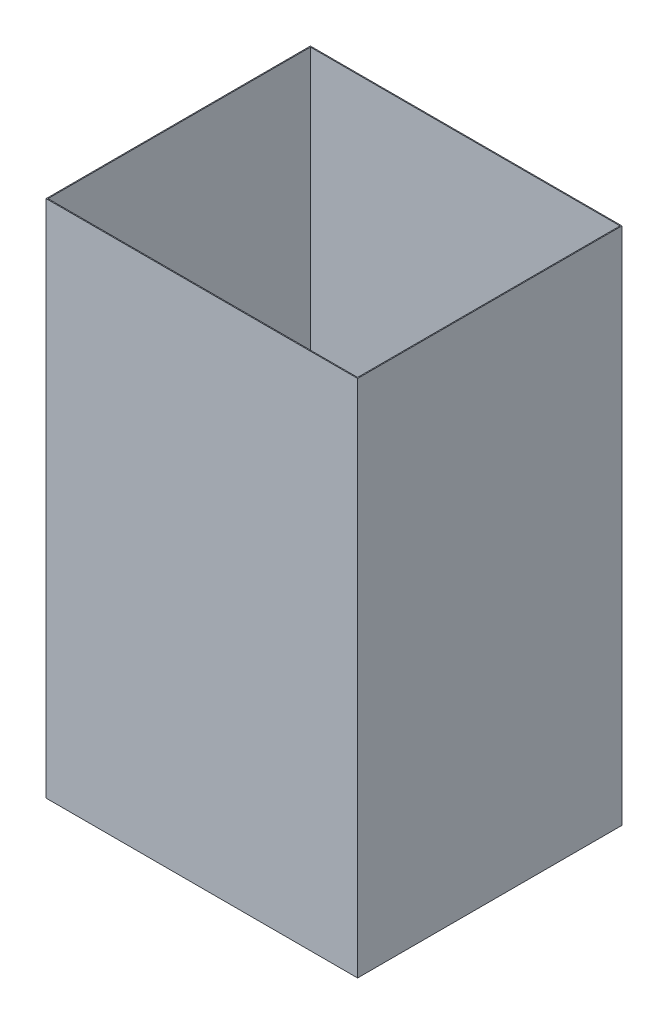
from build123d import *

# Parameters (mm, degrees)
SKETCH1_W           = 838.2
SKETCH1_H           = 711.2
BOSS_EXTRUDE1_DEPTH = 1397
SHELL1_T            = -2.54
CUT_EXTRUDE1_REACH  = 4.54
SKETCH2_W           = 833.12
SKETCH2_H           = 706.12


with BuildPart() as part:
    # Sketch1 → Boss-Extrude1 (new body)
    with BuildSketch(Plane(origin=(0, 0, 0), x_dir=(1, 0, 0), z_dir=(0, 1, 0))):
        with Locations((419.1, 355.6)):
            Rectangle(SKETCH1_W, SKETCH1_H)
    extrude(amount=BOSS_EXTRUDE1_DEPTH)

    # Shell1
    shell1_openings = [part.faces().sort_by_distance(p)[0] for p in [
        (419.1, 0, -355.6),
    ]]
    offset(amount=SHELL1_T, openings=shell1_openings, kind=Kind.INTERSECTION)

    # Sketch2 → Cut-Extrude1 (cut, up to next)
    with BuildSketch(Plane.XZ.offset(-1394.46), mode=Mode.PRIVATE) as cut_extrude1_sk1:
        with Locations((419.1, -355.6)):
            Rectangle(SKETCH2_W, SKETCH2_H)
    cut_extrude1_tool1 = extrude(cut_extrude1_sk1.sketch, amount=-CUT_EXTRUDE1_REACH, mode=Mode.PRIVATE) & part.part
    add(cut_extrude1_tool1.solids().sort_by_distance((419.1, 1394.46, -355.6))[0], mode=Mode.SUBTRACT)


solid = part.part
